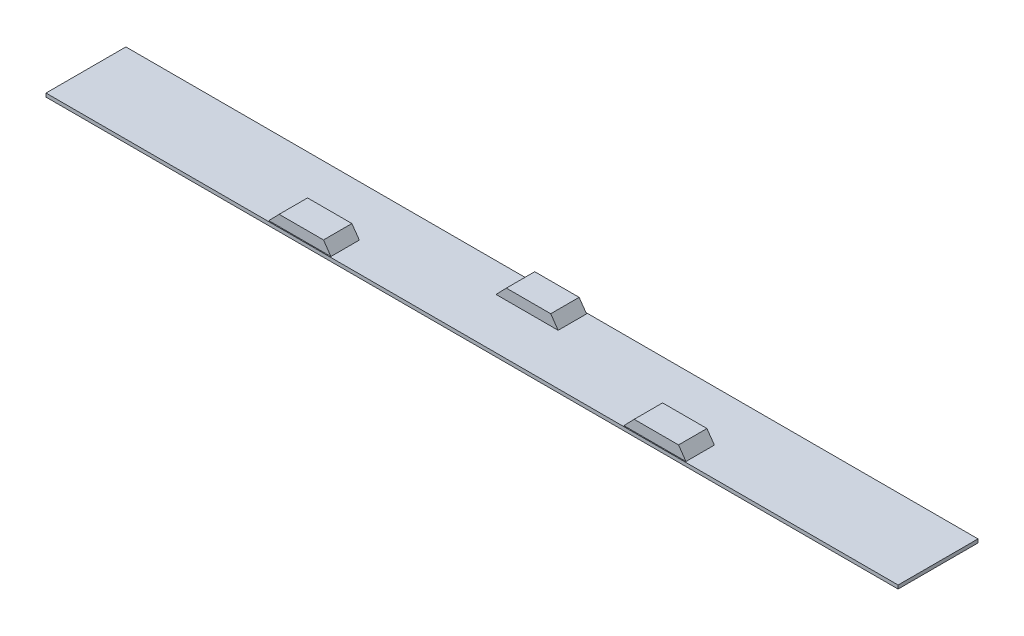
from build123d import *

# Parameters (mm, degrees)
SKETCH1_W           = 2400
SKETCH1_H           = 225
BOSS_EXTRUDE1_DEPTH = 10
BOSS_EXTRUDE2_START = 30
BOSS_EXTRUDE2_DEPTH = 80
BOSS_EXTRUDE3_START = -30
BOSS_EXTRUDE3_DEPTH = 80


with BuildPart() as part:
    # Sketch1 → Boss-Extrude1 (new body)
    with BuildSketch(Plane(origin=(0, 0, 0), x_dir=(1, 0, 0), z_dir=(0, 1, 0))):
        Rectangle(SKETCH1_W, SKETCH1_H)
    extrude(amount=BOSS_EXTRUDE1_DEPTH)

    # Sketch2 → Boss-Extrude2 (add)
    with BuildSketch(Plane.XY.offset(BOSS_EXTRUDE2_START)):
        Polygon((600, 10), (579.09266135, 40), (454.09266135, 40), (425, 10), align=None)
        Polygon((-420.90733865, 40), (-545.90733865, 40), (-575, 10), (-400, 10), align=None)
    extrude(amount=BOSS_EXTRUDE2_DEPTH)

    # Sketch4 → Boss-Extrude3 (add)
    with BuildSketch(Plane.XY.offset(BOSS_EXTRUDE3_START)):
        Polygon((100, 10), (79.09266135, 40), (-45.90733865, 40), (-75, 10), align=None)
    extrude(amount=-BOSS_EXTRUDE3_DEPTH)


solid = part.part
